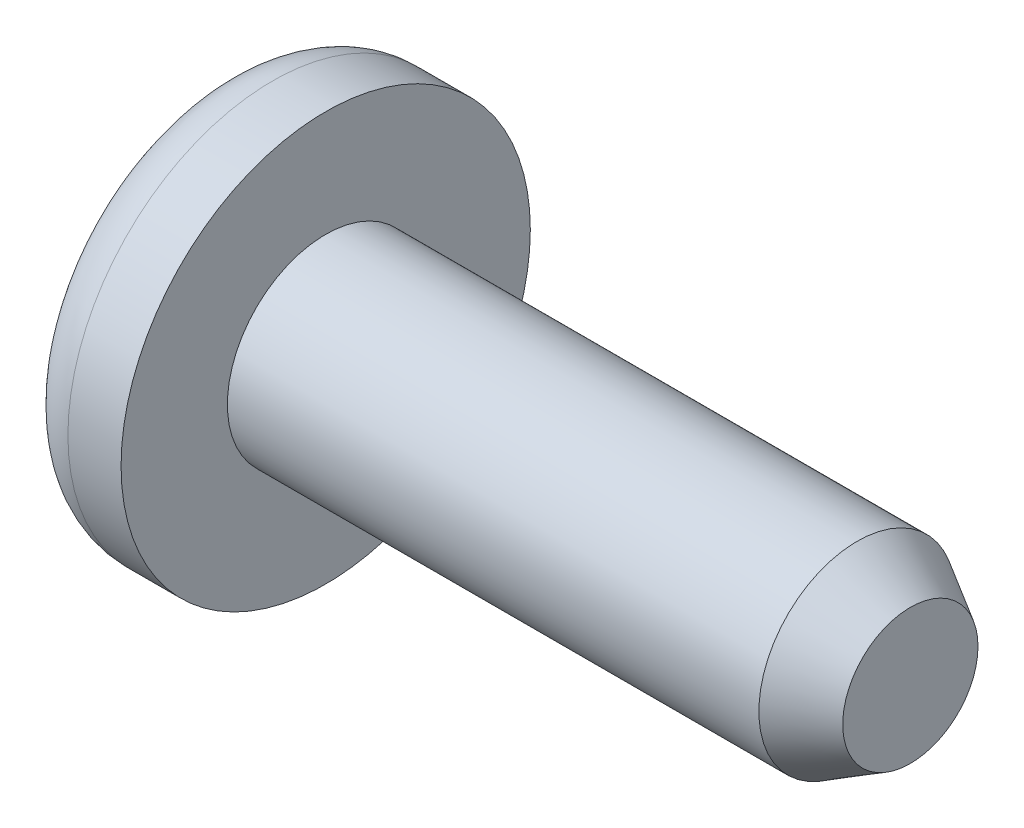
from build123d import *

# Parameters (mm, degrees)
SKETCH1_R           = 2.3495
BOSS_EXTRUDE1_DEPTH = 6.985
CHAMFER1_SIZE       = 1.27
CHAMFER1_SIZE2      = 0.733234842


with BuildPart() as part:
    # Sketch1 → Boss-Extrude1 (new body, symmetric)
    with BuildSketch(Plane(origin=(0, 0, 0), x_dir=(0, 0, -1), z_dir=(1, 0, 0))):
        Circle(SKETCH1_R)
    extrude(amount=BOSS_EXTRUDE1_DEPTH, both=True)

    # Sketch2 → Revolve1 (revolve)
    with BuildSketch(Plane(origin=(0, 0, 0), x_dir=(1, 0, 0), z_dir=(0, 1, 0))):
        with BuildLine():
            Line((-9.525, 0), (-6.985, 0))
            Line((-6.985, 0), (-6.985, -4.8895))
            Line((-6.985, -4.8895), (-8.255, -4.8895))
            ThreePointArc((-8.255, -4.8895), (-9.153025612, -4.517525612), (-9.525, -3.6195))
            Line((-9.525, -3.6195), (-9.525, 0))
        make_face()
    revolve(axis=Axis((-9.525, 0, 0), (1, 0, 0)))

    # Chamfer1
    chamfer1_edges = [part.edges().sort_by_distance(p)[0] for p in [
        (6.985, 0, 2.3495),
    ]]
    chamfer1_side = [part.faces().sort_by_distance(p)[0] for p in [
        (0, 0, 2.3495),
    ]]
    chamfer(chamfer1_edges, length=CHAMFER1_SIZE, length2=CHAMFER1_SIZE2, reference=chamfer1_side[0])


solid = part.part
